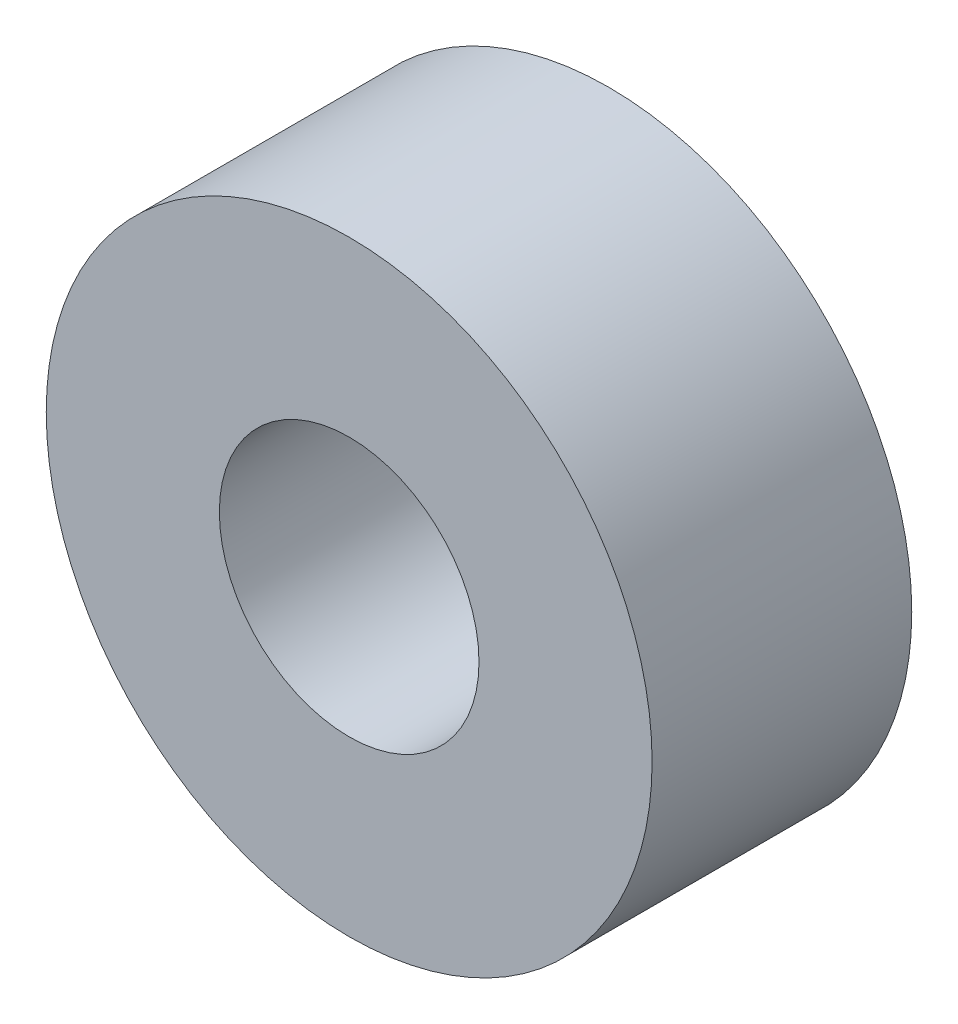
from build123d import *

# Parameters (mm, degrees)
SKETCH1_R           = 3.5
SKETCH1_R_2         = 1.5
BOSS_EXTRUDE1_DEPTH = 1.5


with BuildPart() as part:
    # Sketch1 → Boss-Extrude1 (new body, symmetric)
    with BuildSketch(Plane.XY):
        Circle(SKETCH1_R)
        Circle(SKETCH1_R_2, mode=Mode.SUBTRACT)
    extrude(amount=BOSS_EXTRUDE1_DEPTH, both=True)


solid = part.part
